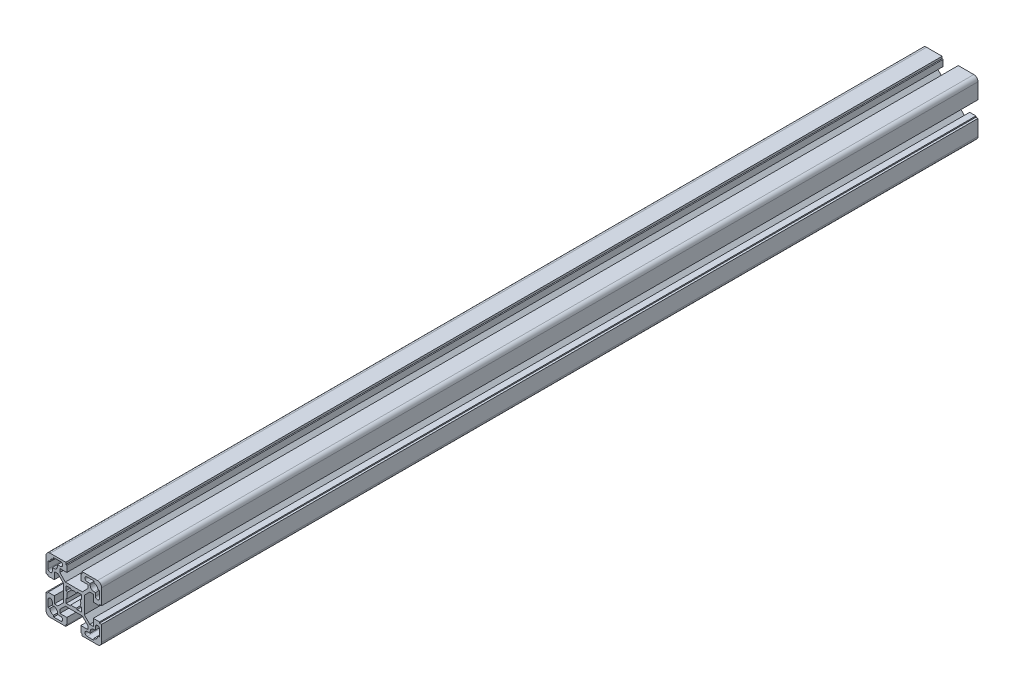
from build123d import *

# Parameters (mm, degrees)
EXTRUDE1_DEPTH = 315


with BuildPart() as part:
    # Sketch1 → Extrude1 (new body, symmetric)
    with BuildSketch(Plane.XY):
        with BuildLine():
            Line((5.8, -20), (17, -20))
            ThreePointArc((17, -20), (19.121320344, -19.121320344), (20, -17))
            Line((20, -17), (20, -5.8))
            Line((20, -5.8), (18.5, -5.8))
            Line((18.5, -5.8), (18.5, -5))
            Line((18.5, -5), (14, -5))
            Line((14, -5), (14, -10.05))
            Line((14, -10.05), (11.464213562, -10.05))
            Line((11.464213562, -10.05), (7.5, -6.085786438))
            Line((7.5, -6.085786438), (7.5, 6.085786438))
            Line((7.5, 6.085786438), (11.464213562, 10.05))
            Line((11.464213562, 10.05), (14, 10.05))
            Line((14, 10.05), (14, 5))
            Line((14, 5), (18.5, 5))
            Line((18.5, 5), (18.5, 5.8))
            Line((18.5, 5.8), (20, 5.8))
            Line((20, 5.8), (20, 17))
            ThreePointArc((20, 17), (19.121320344, 19.121320344), (17, 20))
            Line((17, 20), (5.8, 20))
            Line((5.8, 20), (5.8, 18.5))
            Line((5.8, 18.5), (5, 18.5))
            Line((5, 18.5), (5, 14))
            Line((5, 14), (10.05, 14))
            Line((10.05, 14), (10.05, 11.464213562))
            Line((10.05, 11.464213562), (6.085786438, 7.5))
            Line((6.085786438, 7.5), (-6.085786438, 7.5))
            Line((-6.085786438, 7.5), (-10.05, 11.464213562))
            Line((-10.05, 11.464213562), (-10.05, 14))
            Line((-10.05, 14), (-5, 14))
            Line((-5, 14), (-5, 18.5))
            Line((-5, 18.5), (-5.8, 18.5))
            Line((-5.8, 18.5), (-5.8, 20))
            Line((-5.8, 20), (-17, 20))
            ThreePointArc((-17, 20), (-19.121320344, 19.121320344), (-20, 17))
            Line((-20, 17), (-20, 5.8))
            Line((-20, 5.8), (-18.5, 5.8))
            Line((-18.5, 5.8), (-18.5, 5))
            Line((-18.5, 5), (-14, 5))
            Line((-14, 5), (-14, 10.05))
            Line((-14, 10.05), (-11.464213562, 10.05))
            Line((-11.464213562, 10.05), (-7.5, 6.085786438))
            Line((-7.5, 6.085786438), (-7.5, -6.085786438))
            Line((-7.5, -6.085786438), (-11.464213562, -10.05))
            Line((-11.464213562, -10.05), (-14, -10.05))
            Line((-14, -10.05), (-14, -5))
            Line((-14, -5), (-18.5, -5))
            Line((-18.5, -5), (-18.5, -5.8))
            Line((-18.5, -5.8), (-20, -5.8))
            Line((-20, -5.8), (-20, -17))
            ThreePointArc((-20, -17), (-19.121320344, -19.121320344), (-17, -20))
            Line((-17, -20), (-5.8, -20))
            Line((-5.8, -20), (-5.8, -18.5))
            Line((-5.8, -18.5), (-5, -18.5))
            Line((-5, -18.5), (-5, -14))
            Line((-5, -14), (-10.05, -14))
            Line((-10.05, -14), (-10.05, -11.464213562))
            Line((-10.05, -11.464213562), (-6.085786438, -7.5))
            Line((-6.085786438, -7.5), (6.085786438, -7.5))
            Line((6.085786438, -7.5), (10.05, -11.464213562))
            Line((10.05, -11.464213562), (10.05, -14))
            Line((10.05, -14), (5, -14))
            Line((5, -14), (5, -18.5))
            Line((5, -18.5), (5.8, -18.5))
            Line((5.8, -18.5), (5.8, -20))
        make_face()
        with BuildLine():
            Line((14.5, -18.5), (9.5, -18.5))
            ThreePointArc((9.5, -18.5), (8, -17), (9.5, -15.5))
            Line((9.5, -15.5), (11.75, -15.5))
            Line((11.75, -15.5), (11.75, -14.5))
            ThreePointArc((11.75, -14.5), (12.555456352, -12.555456352), (14.5, -11.75))
            Line((14.5, -11.75), (15.5, -11.75))
            Line((15.5, -11.75), (15.5, -9.5))
            ThreePointArc((15.5, -9.5), (17, -8), (18.5, -9.5))
            Line((18.5, -9.5), (18.5, -14.5))
            Line((18.5, -14.5), (17.25, -14.5))
            ThreePointArc((17.25, -14.5), (16.444543648, -16.444543648), (14.5, -17.25))
            Line((14.5, -17.25), (14.5, -18.5))
        make_face(mode=Mode.SUBTRACT)
        with BuildLine():
            Line((18.5, 14.5), (17.25, 14.5))
            ThreePointArc((17.25, 14.5), (16.444543648, 16.444543648), (14.5, 17.25))
            Line((14.5, 17.25), (14.5, 18.5))
            Line((14.5, 18.5), (9.5, 18.5))
            ThreePointArc((9.5, 18.5), (8, 17), (9.5, 15.5))
            Line((9.5, 15.5), (11.75, 15.5))
            Line((11.75, 15.5), (11.75, 14.5))
            ThreePointArc((11.75, 14.5), (12.555456352, 12.555456352), (14.5, 11.75))
            Line((14.5, 11.75), (15.5, 11.75))
            Line((15.5, 11.75), (15.5, 9.5))
            ThreePointArc((15.5, 9.5), (17, 8), (18.5, 9.5))
            Line((18.5, 9.5), (18.5, 14.5))
        make_face(mode=Mode.SUBTRACT)
        with BuildLine():
            Line((5.5, 5.5), (2.397915762, 5.5))
            Line((2.397915762, 5.5), (1.998263135, 4.583333333))
            ThreePointArc((1.998263135, 4.583333333), (0, 5), (-1.998263135, 4.583333333))
            Line((-1.998263135, 4.583333333), (-2.397915762, 5.5))
            Line((-2.397915762, 5.5), (-5.5, 5.5))
            Line((-5.5, 5.5), (-5.5, 2.397915762))
            Line((-5.5, 2.397915762), (-4.583333333, 1.998263135))
            ThreePointArc((-4.583333333, 1.998263135), (-5, 0), (-4.583333333, -1.998263135))
            Line((-4.583333333, -1.998263135), (-5.5, -2.397915762))
            Line((-5.5, -2.397915762), (-5.5, -5.5))
            Line((-5.5, -5.5), (-2.397915762, -5.5))
            Line((-2.397915762, -5.5), (-1.998263135, -4.583333333))
            ThreePointArc((-1.998263135, -4.583333333), (0, -5), (1.998263135, -4.583333333))
            Line((1.998263135, -4.583333333), (2.397915762, -5.5))
            Line((2.397915762, -5.5), (5.5, -5.5))
            Line((5.5, -5.5), (5.5, -2.397915762))
            Line((5.5, -2.397915762), (4.583333333, -1.998263135))
            ThreePointArc((4.583333333, -1.998263135), (5, 0), (4.583333333, 1.998263135))
            Line((4.583333333, 1.998263135), (5.5, 2.397915762))
            Line((5.5, 2.397915762), (5.5, 5.5))
        make_face(mode=Mode.SUBTRACT)
        with BuildLine():
            Line((-18.5, -14.5), (-17.25, -14.5))
            ThreePointArc((-17.25, -14.5), (-16.444543648, -16.444543648), (-14.5, -17.25))
            Line((-14.5, -17.25), (-14.5, -18.5))
            Line((-14.5, -18.5), (-9.5, -18.5))
            ThreePointArc((-9.5, -18.5), (-8, -17), (-9.5, -15.5))
            Line((-9.5, -15.5), (-11.75, -15.5))
            Line((-11.75, -15.5), (-11.75, -14.5))
            ThreePointArc((-11.75, -14.5), (-12.555456352, -12.555456352), (-14.5, -11.75))
            Line((-14.5, -11.75), (-15.5, -11.75))
            Line((-15.5, -11.75), (-15.5, -9.5))
            ThreePointArc((-15.5, -9.5), (-17, -8), (-18.5, -9.5))
            Line((-18.5, -9.5), (-18.5, -14.5))
        make_face(mode=Mode.SUBTRACT)
        with BuildLine():
            Line((-14.5, 18.5), (-9.5, 18.5))
            ThreePointArc((-9.5, 18.5), (-8, 17), (-9.5, 15.5))
            Line((-9.5, 15.5), (-11.75, 15.5))
            Line((-11.75, 15.5), (-11.75, 14.5))
            ThreePointArc((-11.75, 14.5), (-12.555456352, 12.555456352), (-14.5, 11.75))
            Line((-14.5, 11.75), (-15.5, 11.75))
            Line((-15.5, 11.75), (-15.5, 9.5))
            ThreePointArc((-15.5, 9.5), (-17, 8), (-18.5, 9.5))
            Line((-18.5, 9.5), (-18.5, 14.5))
            Line((-18.5, 14.5), (-17.25, 14.5))
            ThreePointArc((-17.25, 14.5), (-16.444543648, 16.444543648), (-14.5, 17.25))
            Line((-14.5, 17.25), (-14.5, 18.5))
        make_face(mode=Mode.SUBTRACT)
    extrude(amount=EXTRUDE1_DEPTH, both=True)


solid = part.part
